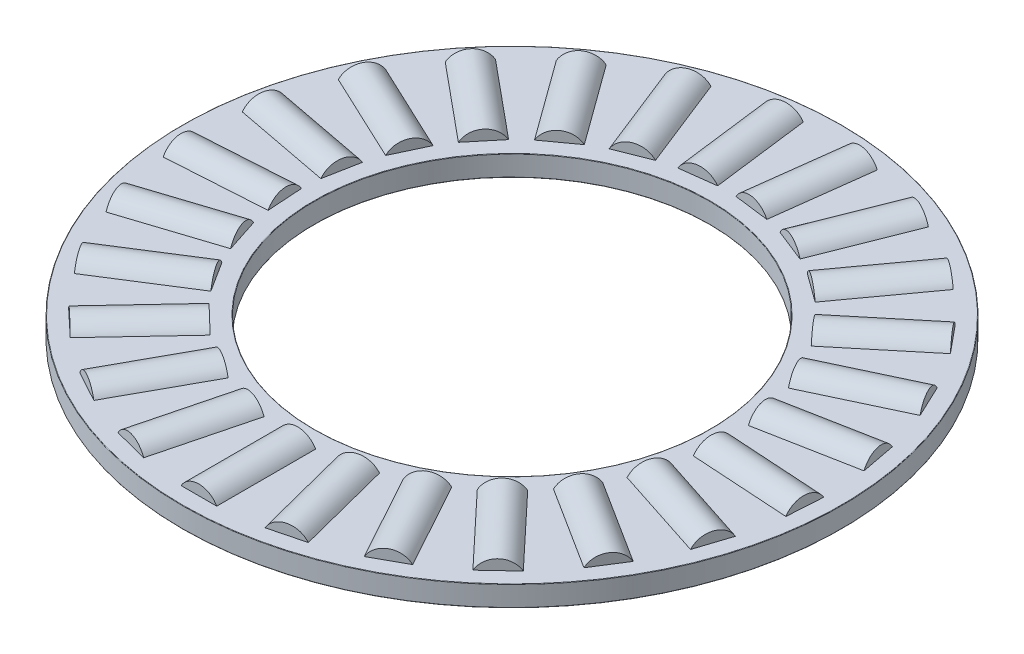
from build123d import *

# Parameters (mm, degrees)
SKETCH1_W         = 6.35
SKETCH1_H         = 0.9921875
SKETCH3_W         = 4.7625
SKETCH3_H         = 0.9921875
SKETCH2_W         = 4.7625
SKETCH2_H         = 0.9921875
CIRPATTERN1_COUNT = 25
CIRPATTERN1_ANGLE = 345.6
CIRPATTERN2_COUNT = 25
FILLET2_R         = 0.01984375


with BuildPart() as part:
    # Sketch1 → Revolve1 (revolve)
    with BuildSketch(Plane(origin=(0, 0, 0), x_dir=(0, 0, -1), z_dir=(1, 0, 0)), mode=Mode.PRIVATE) as revolve1_sk:
        with Locations((-12.7, 0)):
            Rectangle(SKETCH1_W, SKETCH1_H)
    revolve(revolve1_sk.sketch.rotate(Axis((0, -0.9921875, 0), (0, 1, 0)), 180), axis=Axis((0, -0.9921875, 0), (0, 1, 0)))

    # Sketch3 → Cut-Revolve1 (revolve, cut)
    with BuildSketch(Plane(origin=(0, 0, 0), x_dir=(0, 0, -1), z_dir=(1, 0, 0))):
        with Locations((-12.7, 0.49609375)):
            Rectangle(SKETCH3_W, SKETCH3_H)
    cut_revolve1 = revolve(axis=Axis((0, 0, 15.08125), (0, 0, -1)), mode=Mode.SUBTRACT)

    # CirPattern2: Cut-Revolve1 ×25 about axis
    cirpattern2_axis = Axis((0, 0, 0), (0, 1, 0))
    for i in range(1, CIRPATTERN2_COUNT):
        add(cut_revolve1.rotate(cirpattern2_axis, i * 360 / CIRPATTERN2_COUNT), mode=Mode.SUBTRACT)

    # Fillet2
    fillet2_edges = [part.edges().sort_by_distance(p)[0] for p in [
        (0, 0.49609375, 15.875),
        (0, 0.49609375, 9.525),
        (0, -0.49609375, 9.525),
        (0, -0.49609375, 15.875),
    ]]
    fillet(fillet2_edges, radius=FILLET2_R)


with BuildPart() as body_2:
    # Sketch2 → Revolve2 (revolve)
    with BuildSketch(Plane(origin=(0, 0, 0), x_dir=(0, 0, -1), z_dir=(1, 0, 0)), mode=Mode.PRIVATE) as revolve2_sk:
        with Locations((-12.7, 0.49609375)):
            Rectangle(SKETCH2_W, SKETCH2_H)
    revolve(revolve2_sk.sketch.rotate(Axis((0, 0, 15.08125), (0, 0, -1)), 90), axis=Axis((0, 0, 15.08125), (0, 0, -1)))


with BuildPart() as cirpattern1_1:
    # CirPattern1: pattern copy
    add(body_2.part.rotate(Axis((0, 0.9921875, 0), (0, -1, 0)), 1 * CIRPATTERN1_ANGLE / (CIRPATTERN1_COUNT - 1)))


with BuildPart() as cirpattern1_2:
    # CirPattern1: pattern copy
    add(body_2.part.rotate(Axis((0, 0.9921875, 0), (0, -1, 0)), 2 * CIRPATTERN1_ANGLE / (CIRPATTERN1_COUNT - 1)))


with BuildPart() as cirpattern1_3:
    # CirPattern1: pattern copy
    add(body_2.part.rotate(Axis((0, 0.9921875, 0), (0, -1, 0)), 3 * CIRPATTERN1_ANGLE / (CIRPATTERN1_COUNT - 1)))


with BuildPart() as cirpattern1_4:
    # CirPattern1: pattern copy
    add(body_2.part.rotate(Axis((0, 0.9921875, 0), (0, -1, 0)), 4 * CIRPATTERN1_ANGLE / (CIRPATTERN1_COUNT - 1)))


with BuildPart() as cirpattern1_5:
    # CirPattern1: pattern copy
    add(body_2.part.rotate(Axis((0, 0.9921875, 0), (0, -1, 0)), 5 * CIRPATTERN1_ANGLE / (CIRPATTERN1_COUNT - 1)))


with BuildPart() as cirpattern1_6:
    # CirPattern1: pattern copy
    add(body_2.part.rotate(Axis((0, 0.9921875, 0), (0, -1, 0)), 6 * CIRPATTERN1_ANGLE / (CIRPATTERN1_COUNT - 1)))


with BuildPart() as cirpattern1_7:
    # CirPattern1: pattern copy
    add(body_2.part.rotate(Axis((0, 0.9921875, 0), (0, -1, 0)), 7 * CIRPATTERN1_ANGLE / (CIRPATTERN1_COUNT - 1)))


with BuildPart() as cirpattern1_8:
    # CirPattern1: pattern copy
    add(body_2.part.rotate(Axis((0, 0.9921875, 0), (0, -1, 0)), 8 * CIRPATTERN1_ANGLE / (CIRPATTERN1_COUNT - 1)))


with BuildPart() as cirpattern1_9:
    # CirPattern1: pattern copy
    add(body_2.part.rotate(Axis((0, 0.9921875, 0), (0, -1, 0)), 9 * CIRPATTERN1_ANGLE / (CIRPATTERN1_COUNT - 1)))


with BuildPart() as cirpattern1_10:
    # CirPattern1: pattern copy
    add(body_2.part.rotate(Axis((0, 0.9921875, 0), (0, -1, 0)), 10 * CIRPATTERN1_ANGLE / (CIRPATTERN1_COUNT - 1)))


with BuildPart() as cirpattern1_11:
    # CirPattern1: pattern copy
    add(body_2.part.rotate(Axis((0, 0.9921875, 0), (0, -1, 0)), 11 * CIRPATTERN1_ANGLE / (CIRPATTERN1_COUNT - 1)))


with BuildPart() as cirpattern1_12:
    # CirPattern1: pattern copy
    add(body_2.part.rotate(Axis((0, 0.9921875, 0), (0, -1, 0)), 12 * CIRPATTERN1_ANGLE / (CIRPATTERN1_COUNT - 1)))


with BuildPart() as cirpattern1_13:
    # CirPattern1: pattern copy
    add(body_2.part.rotate(Axis((0, 0.9921875, 0), (0, -1, 0)), 13 * CIRPATTERN1_ANGLE / (CIRPATTERN1_COUNT - 1)))


with BuildPart() as cirpattern1_14:
    # CirPattern1: pattern copy
    add(body_2.part.rotate(Axis((0, 0.9921875, 0), (0, -1, 0)), 14 * CIRPATTERN1_ANGLE / (CIRPATTERN1_COUNT - 1)))


with BuildPart() as cirpattern1_15:
    # CirPattern1: pattern copy
    add(body_2.part.rotate(Axis((0, 0.9921875, 0), (0, -1, 0)), 15 * CIRPATTERN1_ANGLE / (CIRPATTERN1_COUNT - 1)))


with BuildPart() as cirpattern1_16:
    # CirPattern1: pattern copy
    add(body_2.part.rotate(Axis((0, 0.9921875, 0), (0, -1, 0)), 16 * CIRPATTERN1_ANGLE / (CIRPATTERN1_COUNT - 1)))


with BuildPart() as cirpattern1_17:
    # CirPattern1: pattern copy
    add(body_2.part.rotate(Axis((0, 0.9921875, 0), (0, -1, 0)), 17 * CIRPATTERN1_ANGLE / (CIRPATTERN1_COUNT - 1)))


with BuildPart() as cirpattern1_18:
    # CirPattern1: pattern copy
    add(body_2.part.rotate(Axis((0, 0.9921875, 0), (0, -1, 0)), 18 * CIRPATTERN1_ANGLE / (CIRPATTERN1_COUNT - 1)))


with BuildPart() as cirpattern1_19:
    # CirPattern1: pattern copy
    add(body_2.part.rotate(Axis((0, 0.9921875, 0), (0, -1, 0)), 19 * CIRPATTERN1_ANGLE / (CIRPATTERN1_COUNT - 1)))


with BuildPart() as cirpattern1_20:
    # CirPattern1: pattern copy
    add(body_2.part.rotate(Axis((0, 0.9921875, 0), (0, -1, 0)), 20 * CIRPATTERN1_ANGLE / (CIRPATTERN1_COUNT - 1)))


with BuildPart() as cirpattern1_21:
    # CirPattern1: pattern copy
    add(body_2.part.rotate(Axis((0, 0.9921875, 0), (0, -1, 0)), 21 * CIRPATTERN1_ANGLE / (CIRPATTERN1_COUNT - 1)))


with BuildPart() as cirpattern1_22:
    # CirPattern1: pattern copy
    add(body_2.part.rotate(Axis((0, 0.9921875, 0), (0, -1, 0)), 22 * CIRPATTERN1_ANGLE / (CIRPATTERN1_COUNT - 1)))


with BuildPart() as cirpattern1_23:
    # CirPattern1: pattern copy
    add(body_2.part.rotate(Axis((0, 0.9921875, 0), (0, -1, 0)), 23 * CIRPATTERN1_ANGLE / (CIRPATTERN1_COUNT - 1)))


with BuildPart() as cirpattern1_24:
    # CirPattern1: pattern copy
    add(body_2.part.rotate(Axis((0, 0.9921875, 0), (0, -1, 0)), 24 * CIRPATTERN1_ANGLE / (CIRPATTERN1_COUNT - 1)))


solid = Compound([part.part, body_2.part, cirpattern1_1.part, cirpattern1_2.part, cirpattern1_3.part, cirpattern1_4.part, cirpattern1_5.part, cirpattern1_6.part, cirpattern1_7.part, cirpattern1_8.part, cirpattern1_9.part, cirpattern1_10.part, cirpattern1_11.part, cirpattern1_12.part, cirpattern1_13.part, cirpattern1_14.part, cirpattern1_15.part, cirpattern1_16.part, cirpattern1_17.part, cirpattern1_18.part, cirpattern1_19.part, cirpattern1_20.part, cirpattern1_21.part, cirpattern1_22.part, cirpattern1_23.part, cirpattern1_24.part])
